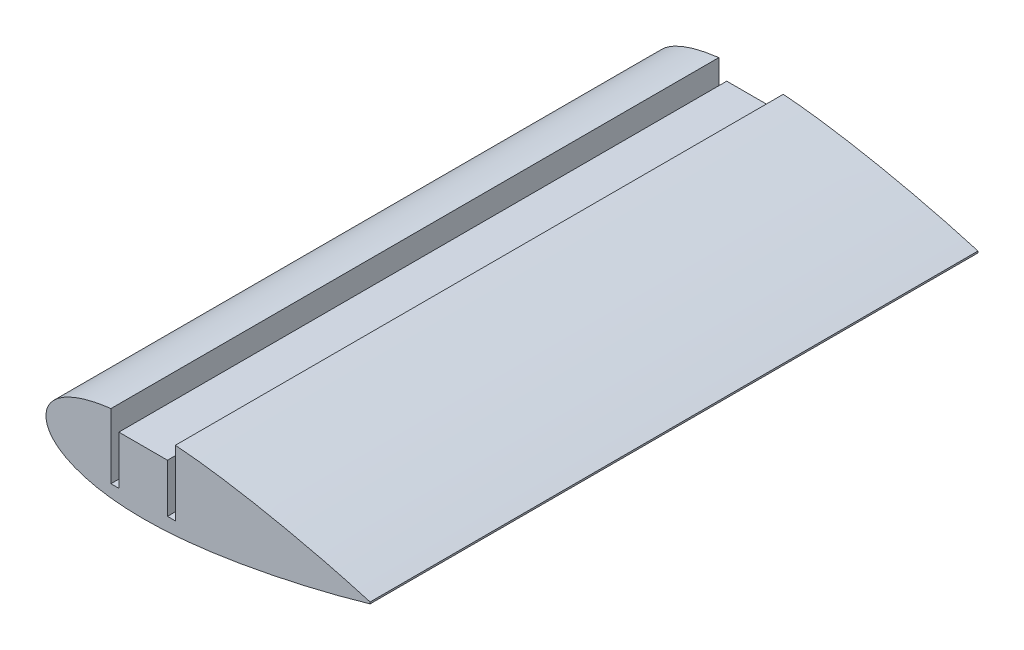
from build123d import *

# Parameters (mm, degrees)
BOSS_EXTRUDE1_DEPTH = 150
CUT_EXTRUDE1_REACH  = 152


with BuildPart() as part:
    # Sketch2 → Boss-Extrude1 (new body)
    with BuildSketch(Plane.XY):
        with BuildLine():
            Line((55.998991919, 0.209938863), (55.998991919, -0.209938863))
            add(Edge.make_bspline(
                [(55.998991919, 0.209938863), (53.463896497, 0.950455214), (48.803904258, 2.233873897), (42.428923908, 3.819934884), (36.743376831, 5.120873453), (31.199749362, 6.287249396), (25.282426203, 7.407488419), (20.176484373, 8.245231015), (14.979623954, 8.974887306), (10.821499069, 9.44862332), (6.697350987, 9.777022894), (3.680655604, 9.939622605), (0.739619613, 10.012665726), (-2.107751213, 9.990028944), (-4.843941705, 9.866960982), (-7.452188048, 9.640899897), (-9.916478705, 9.310630744), (-12.221751766, 8.877222993), (-14.354021752, 8.343659433), (-16.300401345, 7.714341159), (-18.049355518, 6.995399514), (-19.590605164, 6.19339349), (-20.915410238, 5.315562027), (-22.015853697, 4.368064829), (-22.884921184, 3.356491652), (-23.514451457, 2.28497611), (-23.895372624, 1.158788991), (-24.018679664, 0), (-23.895372624, -1.158788991), (-23.514451457, -2.28497611), (-22.884921184, -3.356491652), (-22.015853697, -4.368064829), (-20.915410238, -5.315562027), (-19.590605164, -6.19339349), (-18.049355518, -6.995399514), (-16.300401345, -7.714341159), (-14.354021752, -8.343659433), (-12.221751766, -8.877222993), (-9.916478705, -9.310630744), (-7.452188048, -9.640899897), (-4.843941705, -9.866960982), (-2.107751213, -9.990028944), (0.739619613, -10.012665726), (3.680655604, -9.939622605), (7.74070187, -9.72078634), (12.912832982, -9.241334238), (19.136671313, -8.415754469), (25.28242537, -7.407448977), (31.199752667, -6.287252304), (37.517160947, -4.95809922), (44.742570872, -3.275857272), (51.057566095, -1.626260629), (54.945025722, -0.517808616), (55.95791152, -0.221938691), (55.998991919, -0.209938863)],
                knots=[0, 0, 0, 0, 0.046554703, 0.085193372, 0.115793222, 0.149362634, 0.18504799, 0.221946042, 0.240561295, 0.277549679, 0.295701185, 0.31348255, 0.330796889, 0.347551895, 0.363665842, 0.379065349, 0.393686065, 0.407475418, 0.420391934, 0.432405657, 0.443502806, 0.453686421, 0.462984388, 0.471455944, 0.479204465, 0.486388269, 0.493228974, 0.5, 0.506771026, 0.513611731, 0.520795535, 0.528544056, 0.537015612, 0.546313579, 0.556497194, 0.567594343, 0.579608066, 0.592524582, 0.606313935, 0.620934651, 0.636334158, 0.652448105, 0.669203111, 0.68651745, 0.704298815, 0.740866341, 0.778053958, 0.81495201, 0.850637366, 0.884206778, 0.928744289, 0.981399281, 0.999245596, 1, 1, 1, 1], degree=3))
        make_face()
    extrude(amount=BOSS_EXTRUDE1_DEPTH)

    # Sketch3 → Cut-Extrude1 (cut, up to next)
    with BuildSketch(Plane(origin=(0, 0, 0), x_dir=(-1, 0, 0), z_dir=(0, 0, -1)), mode=Mode.PRIVATE) as cut_extrude1_sk1:
        with BuildLine():
            Line((6, -6.5), (7.95, -6.5))
            Line((7.95, -6.5), (7.95, 9.56370057))
            add(Edge.make_bspline(
                [(-7.95, 9.673763928), (-7.525333967, 9.706496284), (-6.094337758, 9.809525273), (-3.680655604, 9.939622605), (-0.739619613, 10.012665726), (2.107751213, 9.990028944), (4.843941705, 9.866960982), (6.778071836, 9.69932668), (7.798061571, 9.581867182), (7.95, 9.56370057)],
                knots=[0.28819337, 0.28819337, 0.28819337, 0.28819337, 0.295701185, 0.31348255, 0.330796889, 0.347551895, 0.363665842, 0.379065349, 0.381762425, 0.381762425, 0.381762425, 0.381762425], degree=3))
            Line((-7.95, 9.673763928), (-7.95, -6.5))
            Line((-7.95, -6.5), (-6, -6.5))
            Line((-6, -6.5), (-6, 5.5))
            Line((-6, 5.5), (6, 5.5))
            Line((6, 5.5), (6, -6.5))
        make_face()
    cut_extrude1_tool1 = extrude(cut_extrude1_sk1.sketch, amount=-CUT_EXTRUDE1_REACH, mode=Mode.PRIVATE) & part.part
    add(cut_extrude1_tool1.solids().sort_by_distance((-6.975, -6.270858, 0))[0], mode=Mode.SUBTRACT)


solid = part.part
